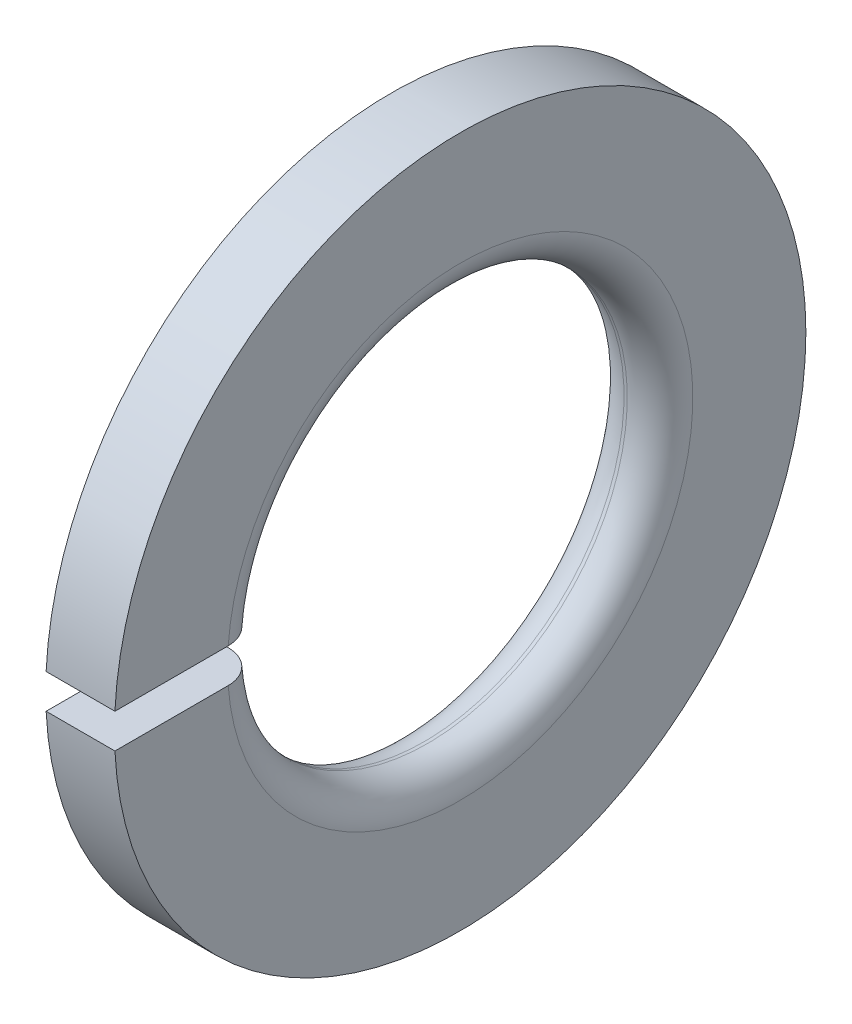
from build123d import *

# Parameters (mm, degrees)
SKETCH2_W = 1.05
SKETCH2_H = 10.761
GAP_DEPTH = 3.1


with BuildPart() as part:
    # Sketch1 → Base-Revolve (revolve)
    with BuildSketch(Plane.XY):
        with BuildLine():
            Line((0, 7.1), (0, 10.55))
            Line((0, 10.55), (-2.1, 10.55))
            Line((-2.1, 10.55), (-2.1, 7.1))
            ThreePointArc((-2.1, 7.1), (-1.807106781, 6.392893219), (-1.1, 6.1))
            Line((-1.1, 6.1), (-1, 6.1))
            ThreePointArc((-1, 6.1), (-0.292893219, 6.392893219), (0, 7.1))
        make_face()
    revolve(axis=Axis((-34.925, 0, 0), (1, 0, 0)))

    # Sketch2 → Gap (cut, through all)
    with BuildSketch(Plane(origin=(0, 0, 0), x_dir=(0, -1, 0), z_dir=(-1, 0, 0))):
        with Locations((0, 5.3805)):
            Rectangle(SKETCH2_W, SKETCH2_H)
    extrude(amount=GAP_DEPTH, mode=Mode.SUBTRACT)


solid = part.part
